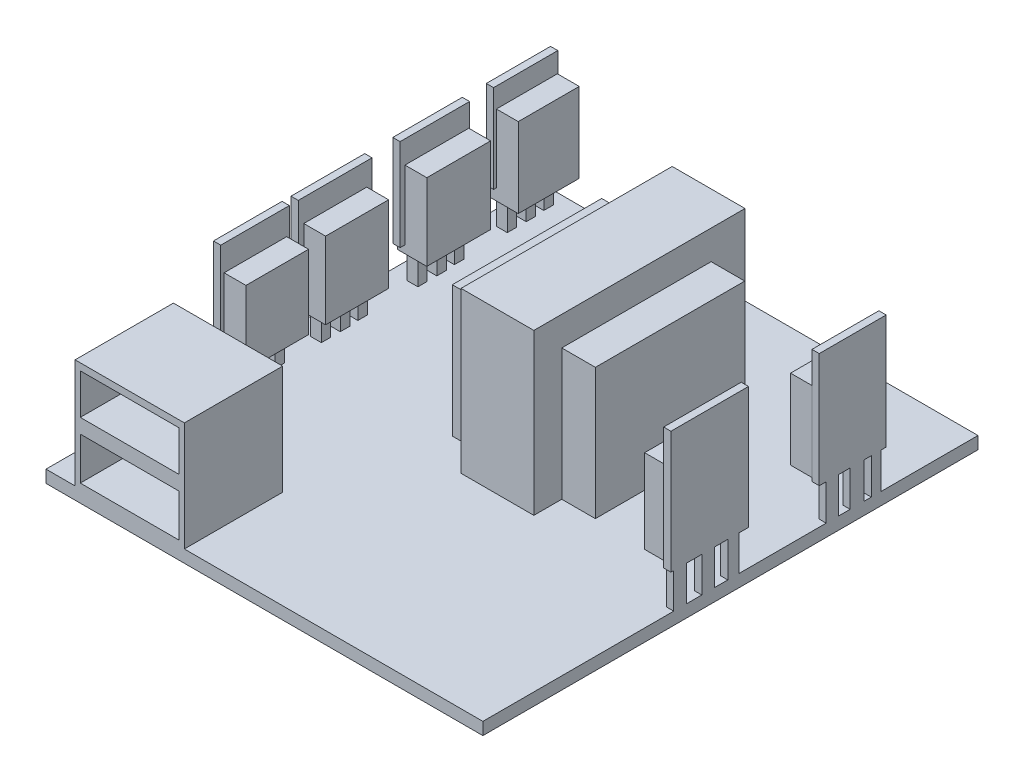
from build123d import *

# Parameters (mm, degrees)
SKETCH1_W             = 60
SKETCH1_H             = 68
BOSS_EXTRUDE1_DEPTH   = 1.7
SKETCH2_W             = 10
SKETCH2_H             = 29
BOSS_EXTRUDE2_DEPTH   = 22
SKETCH3_W             = 19.649144156
SKETCH3_H             = 20.516018163
BOSS_EXTRUDE3_DEPTH   = 18
SKETCH4_W             = 15
SKETCH4_H             = 13.5
BOSS_EXTRUDE4_DEPTH   = 15
SKETCH5_W             = 13.544906357
SKETCH5_H             = 5.539926829
SKETCH5_H_2           = 5.827547791
CUT_EXTRUDE2_DEPTH    = 13
SKETCH6_W             = 9.824572078
SKETCH6_H             = 11.499215045
BOSS_EXTRUDE5_DEPTH   = 4
SKETCH6_W_2           = 9.098893459
SKETCH6_H_2           = 10.941000723
BOSS_EXTRUDE5_2_DEPTH = 4
SKETCH7_W             = 1.787089801
SKETCH7_H             = 6.912356929
SKETCH7_W_2           = 1.768225957
SKETCH7_W_3           = 1.507178671
SKETCH7_W_4           = 1.674642967
SKETCH7_H_2           = 6.465785471
SKETCH7_W_5           = 1.909421345
SKETCH7_W_6           = 1.332290294
BOSS_EXTRUDE6_DEPTH   = 1
SKETCH8_W             = 10.656311419
SKETCH8_H             = 16.762617894
SKETCH8_W_2           = 9.189366045
SKETCH8_H_2           = 15.720989968
BOSS_EXTRUDE7_DEPTH   = 1
SKETCH9_W             = 1.321363234
SKETCH9_H             = 1.321363233
SKETCH9_W_2           = 1.321363233
SKETCH9_H_2           = 1.321363234
SKETCH9_W_3           = 1.517029512
SKETCH9_H_3           = 1.30031101
SKETCH9_H_4           = 1.269763662
SKETCH9_H_5           = 1.300311011
SKETCH9_W_4           = 1.517029513
BOSS_EXTRUDE8_DEPTH   = 12
SKETCH10_W            = 8.373214839
SKETCH10_H            = 10.941000724
SKETCH10_W_2          = 8.763964865
SKETCH10_H_2          = 10.550250698
SKETCH10_W_3          = 8.652322001
SKETCH10_W_4          = 8.596500568
SKETCH10_H_3          = 10.159500672
BOSS_EXTRUDE9_DEPTH   = 4
SKETCH11_W            = 8.819786297
SKETCH11_H            = 12.113250801
SKETCH11_W_2          = 9.545464917
SKETCH11_H_2          = 12.615643692
SKETCH11_W_3          = 10.129411828
SKETCH11_W_4          = 9.423101323
SKETCH11_H_3          = 11.858861387
BOSS_EXTRUDE10_DEPTH  = 1


with BuildPart() as part:
    # Sketch1 → Boss-Extrude1 (new body)
    with BuildSketch(Plane(origin=(0, 0, 0), x_dir=(1, 0, 0), z_dir=(0, 1, 0))):
        with Locations((-2.434210526, -20.447368421)):
            Rectangle(SKETCH1_W, SKETCH1_H)
    extrude(amount=BOSS_EXTRUDE1_DEPTH)

    # Sketch2 → Boss-Extrude2 (add)
    with BuildSketch(Plane(origin=(0, 1.7, 0), x_dir=(1, 0, 0), z_dir=(0, 1, 0))):
        with Locations((1.565789474, -11.947368421)):
            Rectangle(SKETCH2_W, SKETCH2_H)
    extrude(amount=BOSS_EXTRUDE2_DEPTH)

    # Sketch3 → Boss-Extrude3 (add)
    with BuildSketch(Plane(origin=(0, 1.7, 0), x_dir=(1, 0, 0), z_dir=(0, 1, 0))):
        with Locations((1.358363254, -12.356544357)):
            Rectangle(SKETCH3_W, SKETCH3_H)
    extrude(amount=BOSS_EXTRUDE3_DEPTH)

    # Sketch4 → Boss-Extrude4 (add)
    with BuildSketch(Plane(origin=(0, 1.7, 0), x_dir=(1, 0, 0), z_dir=(0, 1, 0))):
        with Locations((-20.934210526, -47.697368421)):
            Rectangle(SKETCH4_W, SKETCH4_H)
    extrude(amount=BOSS_EXTRUDE4_DEPTH)

    # Sketch5 → Cut-Extrude2 (cut)
    with BuildSketch(Plane.XY.offset(54.447368421)):
        with Locations((-20.953791583, 12.977597446)):
            Rectangle(SKETCH5_W, SKETCH5_H)
        with Locations((-20.953791583, 5.306966548)):
            Rectangle(SKETCH5_W, SKETCH5_H_2)
    extrude(amount=-CUT_EXTRUDE2_DEPTH, mode=Mode.SUBTRACT)



with BuildPart() as body_2:
    # Sketch6 → Boss-Extrude5 (new body)
    with BuildSketch(Plane(origin=(27.565789474, 0, 0), x_dir=(0, 0, -1), z_dir=(1, 0, 0))):
        with Locations((-23.322172183, 12.798964349)):
            Rectangle(SKETCH6_W, SKETCH6_H)
    extrude(amount=-BOSS_EXTRUDE5_DEPTH)


with BuildPart() as body_3:
    # Sketch6 → Boss-Extrude5 2 (new body)
    with BuildSketch(Plane(origin=(27.565789474, 0, 0), x_dir=(0, 0, -1), z_dir=(1, 0, 0))):
        with Locations((-3.645117311, 12.519857188)):
            Rectangle(SKETCH6_W_2, SKETCH6_H_2)
    extrude(amount=-BOSS_EXTRUDE5_2_DEPTH)


with BuildPart() as part_1:
    add(part.part)

    add(body_2.part)  # Boss-Extrude6 merges body 2

    add(body_3.part)  # Boss-Extrude6 merges body 3
    # Sketch7 → Boss-Extrude6 (add)
    with BuildSketch(Plane(origin=(27.565789474, 0, 0), x_dir=(0, 0, -1), z_dir=(1, 0, 0))):
        with Locations((-27.340913322, 5.156178464)):
            Rectangle(SKETCH7_W, SKETCH7_H)
        with Locations((-23.498666417, 5.156178464)):
            Rectangle(SKETCH7_W_2, SKETCH7_H)
        with Locations((-20.056618396, 5.156178464)):
            Rectangle(SKETCH7_W_3, SKETCH7_H)
        with Locations((-6.46409964, 4.932892736)):
            Rectangle(SKETCH7_W_4, SKETCH7_H_2)
        with Locations((-3.053245947, 4.932892736)):
            Rectangle(SKETCH7_W_5, SKETCH7_H_2)
        with Locations((-0.439096995, 4.932892736)):
            Rectangle(SKETCH7_W_6, SKETCH7_H_2)
    extrude(amount=-BOSS_EXTRUDE6_DEPTH)

    # Sketch8 → Boss-Extrude7 (add)
    with BuildSketch(Plane(origin=(27.565789474, 0, 0), x_dir=(0, 0, -1), z_dir=(1, 0, 0))):
        with Locations((-23.292544957, 14.912084667)):
            Rectangle(SKETCH8_W, SKETCH8_H)
        with Locations((-3.65570245, 14.483934281)):
            Rectangle(SKETCH8_W_2, SKETCH8_H_2)
    extrude(amount=-BOSS_EXTRUDE7_DEPTH)

    # Sketch9 → Boss-Extrude8 (add)
    with BuildSketch(Plane(origin=(0, 1.7, 0), x_dir=(1, 0, 0), z_dir=(0, 1, 0))):
        with Locations((-29.367713838, -1.42279795)):
            Rectangle(SKETCH9_W, SKETCH9_H)
        with Locations((-29.670931722, 11.160296109)):
            Rectangle(SKETCH9_W_2, SKETCH9_H_2)
        with Locations((-29.639547043, 8.60572197)):
            Rectangle(SKETCH9_W_3, SKETCH9_H_3)
        with Locations((-29.639547043, 5.989826275)):
            Rectangle(SKETCH9_W_3, SKETCH9_H_4)
        with Locations((-29.336329159, -3.97737209)):
            Rectangle(SKETCH9_W_3, SKETCH9_H_5)
        with Locations((-29.336329159, -6.593267784)):
            Rectangle(SKETCH9_W_3, SKETCH9_H_4)
        with Locations((-29.357446593, -14.692498665)):
            Rectangle(SKETCH9_W_2, SKETCH9_H)
        with Locations((-29.326061914, -17.247072804)):
            Rectangle(SKETCH9_W_3, SKETCH9_H_3)
        with Locations((-29.326061914, -19.862968498)):
            Rectangle(SKETCH9_W_3, SKETCH9_H_4)
        with Locations((-29.34335534, -26.079899051)):
            Rectangle(SKETCH9_W, SKETCH9_H)
        with Locations((-29.311970662, -28.63447319)):
            Rectangle(SKETCH9_W_4, SKETCH9_H_3)
        with Locations((-29.311970662, -31.250368885)):
            Rectangle(SKETCH9_W_4, SKETCH9_H_4)
    extrude(amount=BOSS_EXTRUDE8_DEPTH)

    # Sketch10 → Boss-Extrude9 (add)
    with BuildSketch(Plane.ZY.offset(30.331613338)):
        with Locations((-8.496044207, 11.235964245)):
            Rectangle(SKETCH10_W, SKETCH10_H)
        with Locations((3.86840304, 11.040589232)):
            Rectangle(SKETCH10_W_2, SKETCH10_H_2)
        with Locations((17.823761105, 11.040589232)):
            Rectangle(SKETCH10_W_3, SKETCH10_H_2)
        with Locations((28.792672544, 10.845214219)):
            Rectangle(SKETCH10_W_4, SKETCH10_H_3)
    extrude(amount=-BOSS_EXTRUDE9_DEPTH)

    # Sketch11 → Boss-Extrude10 (add)
    with BuildSketch(Plane.ZY.offset(30.331613338)):
        with Locations((-8.32857991, 13.385089388)):
            Rectangle(SKETCH11_W, SKETCH11_H)
        with Locations((4.147510201, 13.133892942)):
            Rectangle(SKETCH11_W_2, SKETCH11_H_2)
        with Locations((17.836627399, 13.385089388)):
            Rectangle(SKETCH11_W_3, SKETCH11_H)
        with Locations((28.841568651, 13.512284095)):
            Rectangle(SKETCH11_W_4, SKETCH11_H_3)
    extrude(amount=-BOSS_EXTRUDE10_DEPTH)


solid = part_1.part
